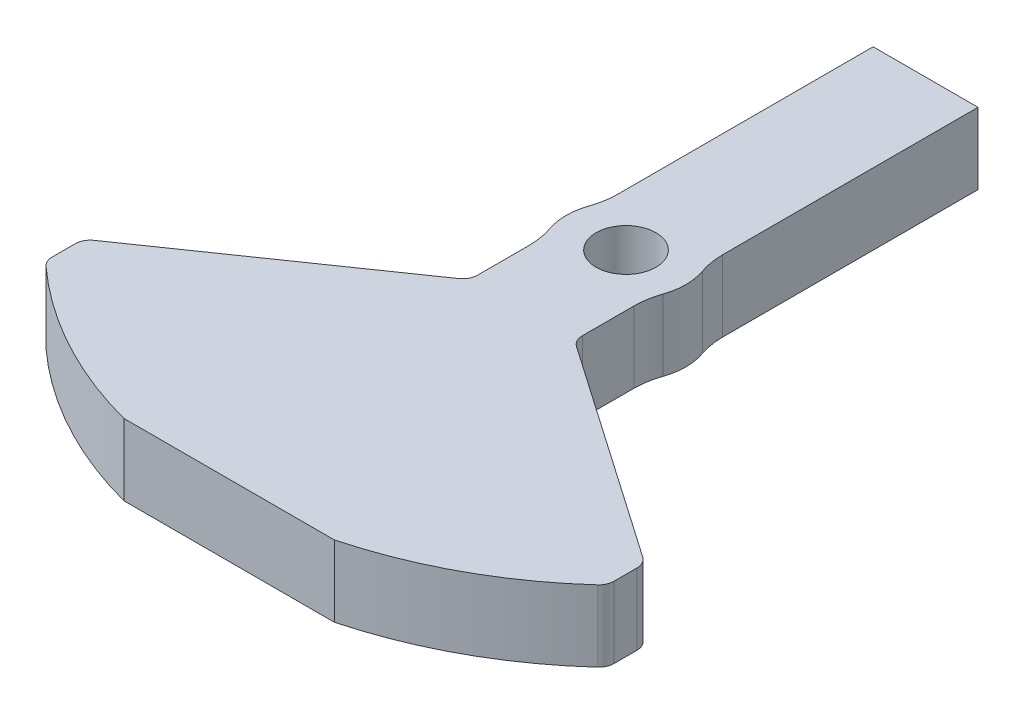
from build123d import *

# Parameters (mm, degrees)
SKETCH1_R                  = 4
BOSS_EXTRUDE1_DEPTH        = 9.525
FILLET1_R                  = 10
M8X1_25_TAPPED_HOLE1_D     = 6.8
M8X1_25_TAPPED_HOLE1_DEPTH = 32.25
M8X1_25_TAPPED_HOLE1_TIP   = 2.042926105
FILLET2_R                  = 2


with BuildPart() as part:
    # Sketch1 → Boss-Extrude1 (new body)
    with BuildSketch(Plane(origin=(0, 0, 0), x_dir=(1, 0, 0), z_dir=(0, 1, 0))):
        with BuildLine():
            Line((-7, 40), (7, 40))
            Line((7, 40), (7, 3.872983346))
            ThreePointArc((7, 3.872983346), (8, 0), (7, -3.872983346))
            Line((7, -3.872983346), (7, -13.872983346))
            Line((7, -13.872983346), (37.5, -35))
            Line((37.5, -35), (37.5, -40))
            ThreePointArc((37.5, -40), (26.579328871, -47.956118241), (14.044571905, -53))
            Line((14.044571905, -53), (-14.044571905, -53))
            ThreePointArc((-14.044571905, -53), (-26.579328871, -47.956118241), (-37.5, -40))
            Line((-37.5, -40), (-37.5, -35))
            Line((-37.5, -35), (-7, -13.872983346))
            Line((-7, -13.872983346), (-7, -3.872983346))
            ThreePointArc((-7, -3.872983346), (-8, 0), (-7, 3.872983346))
            Line((-7, 3.872983346), (-7, 40))
        make_face()
        Circle(SKETCH1_R, mode=Mode.SUBTRACT)
    extrude(amount=BOSS_EXTRUDE1_DEPTH)

    # Fillet1
    fillet1_edges = [part.edges().sort_by_distance(p)[0] for p in [
        (7, 4.7625, -3.872983346),
        (7, 4.7625, 3.872983346),
        (-7, 4.7625, 3.872983346),
        (-7, 4.7625, -3.872983346),
    ]]
    fillet(fillet1_edges, radius=FILLET1_R)

    # M8x1.25 Tapped Hole1
    with Locations(Plane(origin=(0, 0, -40), x_dir=(-1, 0, 0), z_dir=(0, 0, -1))):
        with Locations((0, 4.7625)):
            Hole(M8X1_25_TAPPED_HOLE1_D / 2, depth=M8X1_25_TAPPED_HOLE1_DEPTH)
            with Locations((0, 0, -(M8X1_25_TAPPED_HOLE1_DEPTH + M8X1_25_TAPPED_HOLE1_TIP / 2))):  # 118° drill point
                Cone(0, M8X1_25_TAPPED_HOLE1_D / 2, M8X1_25_TAPPED_HOLE1_TIP, mode=Mode.SUBTRACT)

    # Fillet2
    fillet2_edges = [part.edges().sort_by_distance(p)[0] for p in [
        (7, 4.7625, 13.872983346),
        (37.5, 4.7625, 35),
        (37.5, 4.7625, 40),
        (-37.5, 4.7625, 40),
        (-37.5, 4.7625, 35),
        (-7, 4.7625, 13.872983346),
    ]]
    fillet(fillet2_edges, radius=FILLET2_R)


solid = part.part
